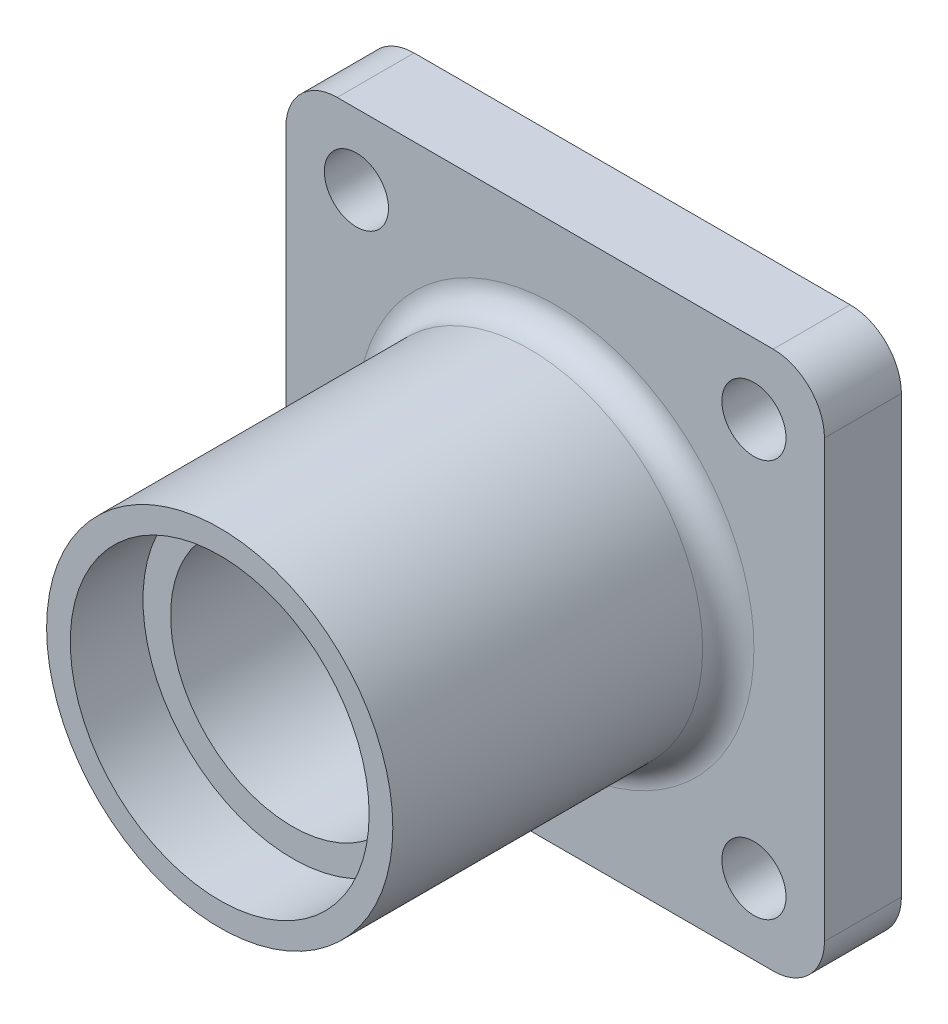
from build123d import *

# Parameters (mm, degrees)
SKETCH1_R                = 21.43125
SKETCH1_R_2              = 15.08125
BOSS_EXTRUDE1_DEPTH      = 28.2575
BOSS_EXTRUDE1_DEPTH_BACK = 28.2575
SKETCH2_R                = 3.96875
SKETCH2_R_2              = 20.6375
BOSS_EXTRUDE2_DEPTH      = 9.525
SKETCH3_R                = 18.5
CUT_EXTRUDE1_DEPTH       = 9
FILLET1_R                = 3.175


with BuildPart() as part:
    # Sketch1 → Boss-Extrude1 (new body, two sides)
    with BuildSketch(Plane.XY) as boss_extrude1_sk:
        Circle(SKETCH1_R)
        Circle(SKETCH1_R_2, mode=Mode.SUBTRACT)
    extrude(amount=BOSS_EXTRUDE1_DEPTH)
    extrude(boss_extrude1_sk.sketch, amount=-BOSS_EXTRUDE1_DEPTH_BACK)

    # Sketch2 → Boss-Extrude2 (add)
    with BuildSketch(Plane.XY.offset(-22.7965)):
        with BuildLine():
            Line((-26.9875, 33.3375), (26.9875, 33.3375))
            ThreePointArc((26.9875, 33.3375), (31.477628061, 31.477628061), (33.3375, 26.9875))
            Line((33.3375, 26.9875), (33.3375, -26.9875))
            ThreePointArc((33.3375, -26.9875), (31.477628061, -31.477628061), (26.9875, -33.3375))
            Line((26.9875, -33.3375), (-26.9875, -33.3375))
            ThreePointArc((-26.9875, -33.3375), (-31.477628061, -31.477628061), (-33.3375, -26.9875))
            Line((-33.3375, -26.9875), (-33.3375, 26.9875))
            ThreePointArc((-33.3375, 26.9875), (-31.477628061, 31.477628061), (-26.9875, 33.3375))
        make_face()
        with Locations((-24.60625, 24.60625)):
            Circle(SKETCH2_R, mode=Mode.SUBTRACT)
        with Locations((24.60625, 24.60625)):
            Circle(SKETCH2_R, mode=Mode.SUBTRACT)
        with Locations((24.60625, -24.60625)):
            Circle(SKETCH2_R, mode=Mode.SUBTRACT)
        with Locations((-24.60625, -24.60625)):
            Circle(SKETCH2_R, mode=Mode.SUBTRACT)
        Circle(SKETCH2_R_2, mode=Mode.SUBTRACT)
    extrude(amount=BOSS_EXTRUDE2_DEPTH)

    # Sketch3 → Cut-Extrude1 (cut)
    with BuildSketch(Plane.XY.offset(28.2575)):
        Circle(SKETCH3_R)
    cut_extrude1 = extrude(amount=-CUT_EXTRUDE1_DEPTH, mode=Mode.SUBTRACT)

    # Mirror1: Cut-Extrude1 across plane
    add(cut_extrude1.mirror(Plane.XY), mode=Mode.SUBTRACT)

    # Fillet1
    fillet1_edges = [part.edges().sort_by_distance(p)[0] for p in [
        (-21.43125, 0, -13.2715),
    ]]
    fillet(fillet1_edges, radius=FILLET1_R)


solid = part.part
